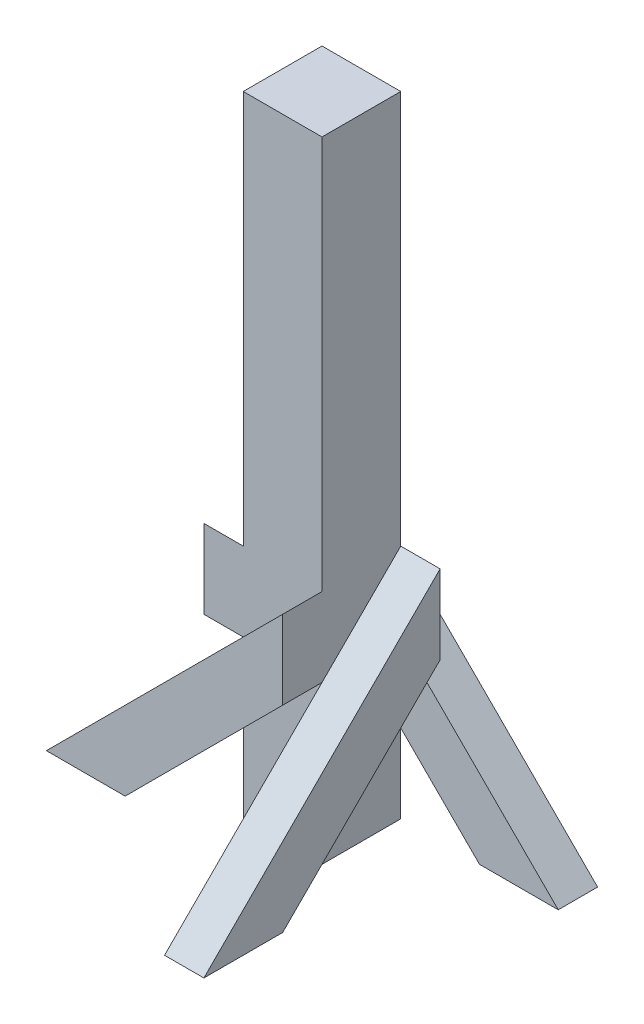
from build123d import *

# Parameters (mm, degrees)
SKETCH1_W           = 101.6
SKETCH1_H           = 101.6
BOSS_EXTRUDE1_DEPTH = 812.8
BOSS_EXTRUDE2_DEPTH = 50.8
BOSS_EXTRUDE3_DEPTH = 50.8
BOSS_EXTRUDE4_DEPTH = 50.8
BOSS_EXTRUDE6_DEPTH = 50.8


with BuildPart() as part:
    # Sketch1 → Boss-Extrude1 (new body)
    with BuildSketch(Plane(origin=(0, 0, 0), x_dir=(1, 0, 0), z_dir=(0, 1, 0))):
        with Locations((-7.112, 11.176)):
            Rectangle(SKETCH1_W, SKETCH1_H)
    extrude(amount=BOSS_EXTRUDE1_DEPTH)

    # Sketch2 → Boss-Extrude2 (add)
    with BuildSketch(Plane.ZY.offset(57.912)):
        Polygon((-163.576, 0), (39.624, 203.2), (39.624, 304.8), (-265.176, 0), align=None)
    extrude(amount=BOSS_EXTRUDE2_DEPTH)

    # Sketch3 → Boss-Extrude3 (add)
    with BuildSketch(Plane(origin=(0, 0, -61.976), x_dir=(-1, 0, 0), z_dir=(0, 0, -1))):
        Polygon((-145.288, 0), (57.912, 203.2), (57.912, 304.8), (-246.888, 0), align=None)
    extrude(amount=BOSS_EXTRUDE3_DEPTH)

    # Sketch5 → Boss-Extrude4 (add)
    with BuildSketch(Plane.XY.offset(39.624)):
        Polygon((-159.512, 0), (43.688, 203.2), (43.688, 304.8), (-261.112, 0), align=None)
    extrude(amount=BOSS_EXTRUDE4_DEPTH)

    # Sketch7 → Boss-Extrude6 (add)
    with BuildSketch(Plane(origin=(43.688, 0, 0), x_dir=(0, 0, -1), z_dir=(1, 0, 0))):
        Polygon((-141.224, 0), (61.976, 203.2), (61.976, 304.8), (-242.824, 0), align=None)
    extrude(amount=BOSS_EXTRUDE6_DEPTH)


solid = part.part
